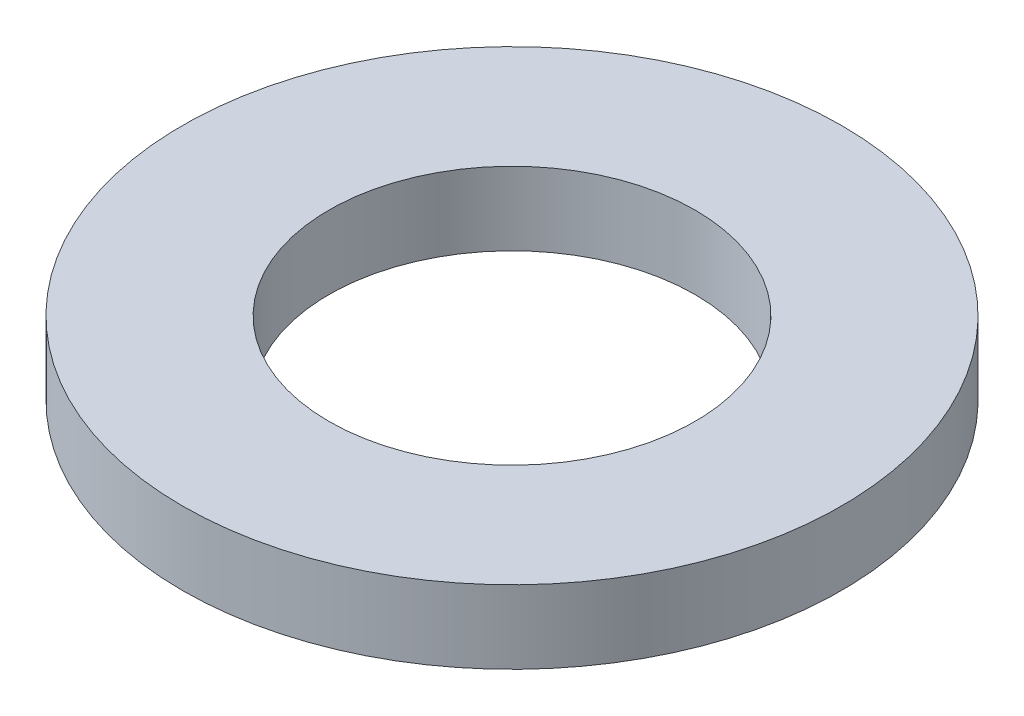
from build123d import *

# Parameters (mm, degrees)
SKETCH1_R           = 45
SKETCH1_R_2         = 25
BOSS_EXTRUDE1_DEPTH = 10


with BuildPart() as part:
    # Sketch1 → Boss-Extrude1 (new body)
    with BuildSketch(Plane(origin=(0, 0, 0), x_dir=(1, 0, 0), z_dir=(0, 1, 0))):
        Circle(SKETCH1_R)
        Circle(SKETCH1_R_2, mode=Mode.SUBTRACT)
    extrude(amount=BOSS_EXTRUDE1_DEPTH)


solid = part.part
